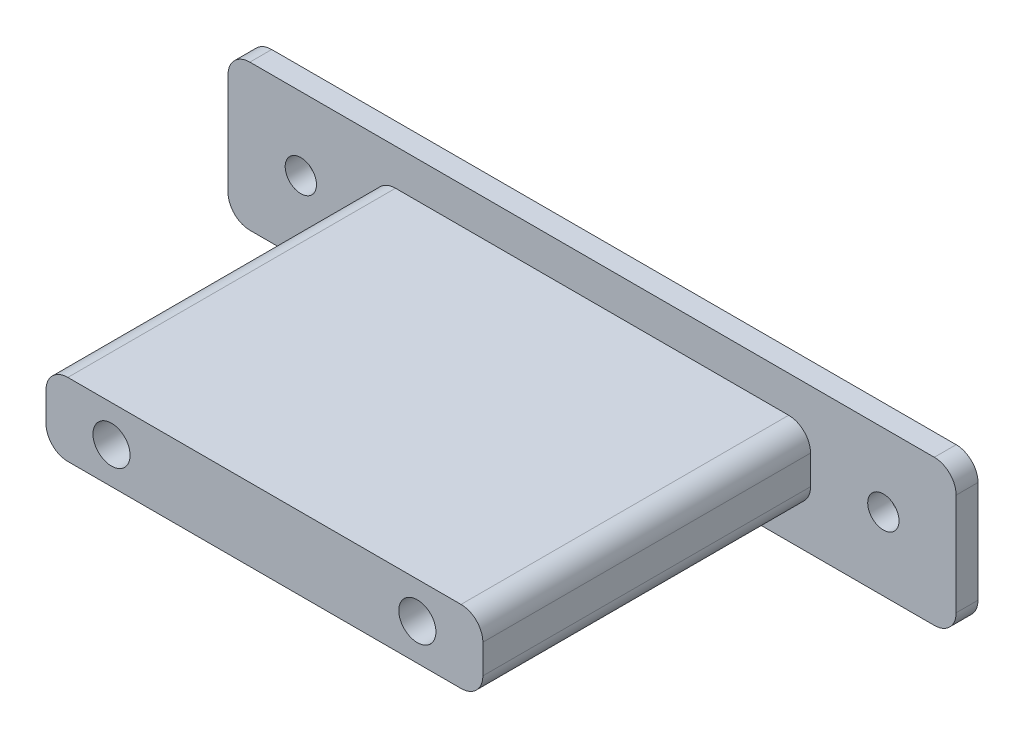
from build123d import *

# Parameters (mm, degrees)
SKETCH1_W           = 100
SKETCH1_H           = 20
SKETCH1_R           = 2.15
SKETCH1_R_2         = 2.55
BOSS_EXTRUDE1_DEPTH = 3
SKETCH2_R           = 2.55
BOSS_EXTRUDE3_DEPTH = 3
SKETCH3_W           = 60
SKETCH3_H           = 10
BOSS_EXTRUDE4_DEPTH = 45
SKETCH4_R           = 2.55
CUT_EXTRUDE3_DEPTH  = 8
FILLET1_R           = 3


with BuildPart() as part:
    # Sketch1 → Boss-Extrude1 (new body)
    with BuildSketch(Plane.XY):
        with Locations((50, -10)):
            Rectangle(SKETCH1_W, SKETCH1_H)
        with Locations((10, -10)):
            Circle(SKETCH1_R, mode=Mode.SUBTRACT)
        with Locations((90, -10)):
            Circle(SKETCH1_R, mode=Mode.SUBTRACT)
        with Locations((29, -10)):
            Circle(SKETCH1_R_2, mode=Mode.SUBTRACT)
        with Locations((71, -10)):
            Circle(SKETCH1_R_2, mode=Mode.SUBTRACT)
    extrude(amount=BOSS_EXTRUDE1_DEPTH)

    # Sketch2 → Boss-Extrude3 (add)
    with BuildSketch(Plane.XY.offset(3)):
        with Locations((71, -10)):
            Circle(SKETCH2_R)
        with Locations((29, -10)):
            Circle(SKETCH2_R)
    extrude(amount=-BOSS_EXTRUDE3_DEPTH)

    # Sketch3 → Boss-Extrude4 (add)
    with BuildSketch(Plane.XY.offset(3)):
        with Locations((50, -10)):
            Rectangle(SKETCH3_W, SKETCH3_H)
    extrude(amount=BOSS_EXTRUDE4_DEPTH)

    # Sketch4 → Cut-Extrude3 (cut)
    with BuildSketch(Plane.XY.offset(48)):
        with Locations((71, -10)):
            Circle(SKETCH4_R)
        with Locations((29, -10)):
            Circle(SKETCH4_R)
    extrude(amount=-CUT_EXTRUDE3_DEPTH, mode=Mode.SUBTRACT)

    # Fillet1
    fillet1_edges = [part.edges().sort_by_distance(p)[0] for p in [
        (80, -15, 25.5),
        (80, -5, 25.5),
        (20, -5, 25.5),
        (20, -15, 25.5),
        (0, 0, 1.5),
        (100, 0, 1.5),
        (100, -20, 1.5),
        (0, -20, 1.5),
    ]]
    fillet(fillet1_edges, radius=FILLET1_R)


solid = part.part
